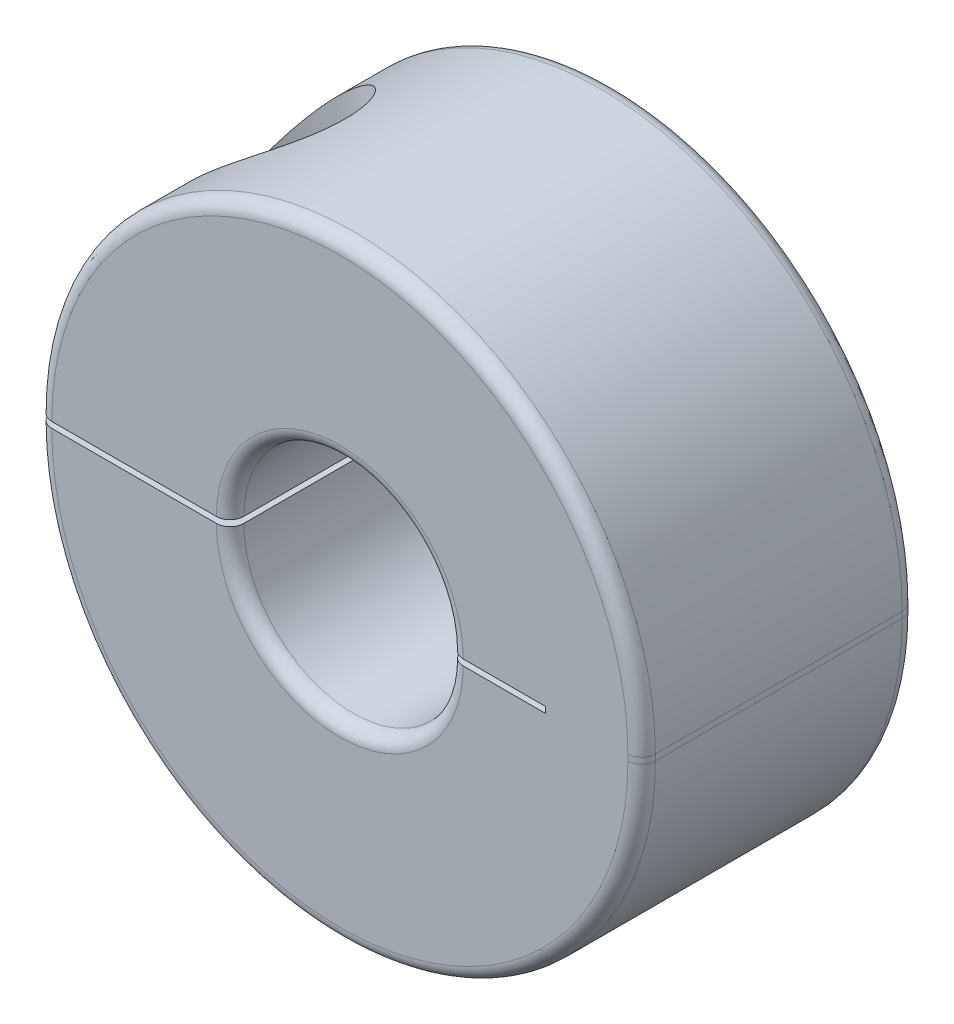
from build123d import *

# Parameters (mm, degrees)
EXTRUDE1_DEPTH     = 3.96875
CUT_EXTRUDE2_DEPTH = 1.4224
FILLET1_R          = 0.396875
FILLET2_R          = 0.396875
CHAMFER2_SIZE      = 0.254


with BuildPart() as part:
    # Sketch1 → Extrude1 (new body, symmetric)
    with BuildSketch(Plane.XY):
        with BuildLine():
            Line((-8.73125, 0.0873125), (-3.175, 0.0873125))
            ThreePointArc((-3.175, 0.0873125), (0, 3.2623125), (3.175, 0.0873125))
            Line((3.175, 0.0873125), (5.953125, 0.0873125))
            Line((5.953125, 0.0873125), (5.953125, -0.0873125))
            Line((5.953125, -0.0873125), (3.175, -0.0873125))
            ThreePointArc((3.175, -0.0873125), (0, -3.2623125), (-3.175, -0.0873125))
            Line((-3.175, -0.0873125), (-8.73125, -0.0873125))
            ThreePointArc((-8.73125, -0.0873125), (0, -8.8185625), (8.73125, -0.0873125))
            Line((8.73125, -0.0873125), (8.73125, 0.0873125))
            ThreePointArc((8.73125, 0.0873125), (0, 8.8185625), (-8.73125, 0.0873125))
        make_face()
    extrude(amount=EXTRUDE1_DEPTH, both=True)

    # Sketch4 → Cut-Revolve1 (revolve, cut)
    with BuildSketch(Plane.XY):
        Polygon((-5.953125, 8.8185625), (-3.819525, 8.8185625), (-3.819525, 0.7985125), (-4.530725, 0.7985125), (-4.530725, -8.8185625), (-5.953125, -8.8185625), align=None)
    revolve(axis=Axis((-5.953125, -8.8185625, 0), (0, 1, 0)), mode=Mode.SUBTRACT)

    # Fillet1
    fillet1_edges = [part.edges().sort_by_distance(p)[0] for p in [
        (0, 3.2623125, 3.96875),
        (0, 3.2623125, -3.96875),
        (0, 8.8185625, -3.96875),
        (0, -8.8185625, 3.96875),
        (8.73125, 0, 3.96875),
        (0, 8.8185625, 3.96875),
        (8.73125, 0, -3.96875),
        (0, -8.8185625, -3.96875),
    ]]
    fillet(fillet1_edges, radius=FILLET1_R)

    # Fillet2
    fillet2_edges = [part.edges().sort_by_distance(p)[0] for p in [
        (0, -3.2623125, 3.96875),
        (0, -3.2623125, -3.96875),
    ]]
    fillet(fillet2_edges, radius=FILLET2_R)


with BuildPart() as body_2:
    # Sketch6 → Revolve1 (revolve)
    with BuildSketch(Plane.XY):
        Polygon((-5.953125, 3.6433125), (-3.819525, 3.6433125), (-3.819525, 0.7985125), (-4.530725, 0.7985125), (-4.530725, -4.8910875), (-5.953125, -4.8910875), align=None)
    revolve(axis=Axis((-5.953125, -4.8910875, 0), (0, 1, 0)))

    # Sketch7 → Cut-Extrude2 (cut)
    with BuildSketch(Plane(origin=(0, 3.6433125, 0), x_dir=(-1, 0, 0), z_dir=(0, 1, 0))):
        Polygon((5.953125, -1.313956837), (7.091045, -0.656978418), (7.091045, 0.656978418), (5.953125, 1.313956837), (4.815205, 0.656978418), (4.815205, -0.656978418), align=None)
    extrude(amount=-CUT_EXTRUDE2_DEPTH, mode=Mode.SUBTRACT)

    # Chamfer2
    chamfer2_edges = [body_2.edges().sort_by_distance(p)[0] for p in [
        (-8.086725, 3.6433125, 0),
    ]]
    chamfer(chamfer2_edges, length=CHAMFER2_SIZE)


solid = Compound([part.part, body_2.part])
